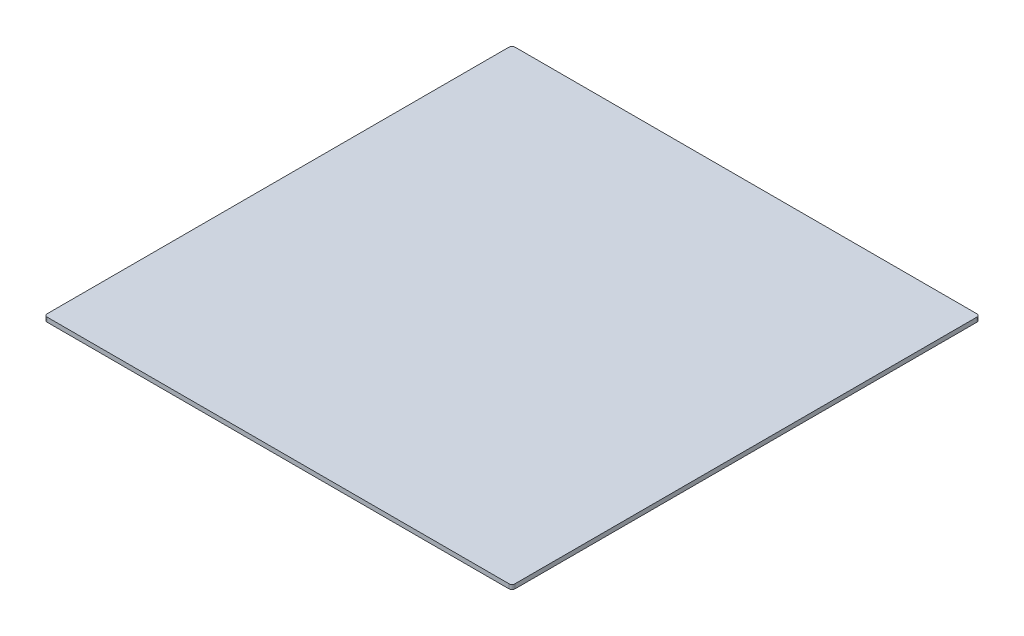
from build123d import *

# Parameters (mm, degrees)
SKETCH1_W           = 315
SKETCH1_H           = 315
BOSS_EXTRUDE1_DEPTH = 3
FILLET1_R           = 2


with BuildPart() as part:
    # Sketch1 → Boss-Extrude1 (new body)
    with BuildSketch(Plane(origin=(0, 0, 0), x_dir=(1, 0, 0), z_dir=(0, 1, 0))):
        Rectangle(SKETCH1_W, SKETCH1_H)
    extrude(amount=BOSS_EXTRUDE1_DEPTH)

    # Fillet1
    fillet1_edges = [part.edges().sort_by_distance(p)[0] for p in [
        (-157.5, 1.5, -157.5),
        (157.5, 1.5, -157.5),
        (157.5, 1.5, 157.5),
        (-157.5, 1.5, 157.5),
    ]]
    fillet(fillet1_edges, radius=FILLET1_R)


solid = part.part
